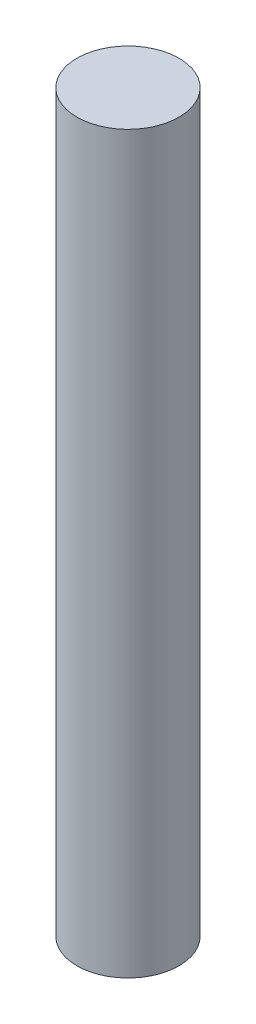
from build123d import *

# Parameters (mm, degrees)
SKETCH1_R           = 3.175
BOSS_EXTRUDE1_DEPTH = 45.72


with BuildPart() as part:
    # Sketch1 → Boss-Extrude1 (new body)
    with BuildSketch(Plane(origin=(0, 0, 0), x_dir=(1, 0, 0), z_dir=(0, 1, 0))):
        Circle(SKETCH1_R)
    extrude(amount=BOSS_EXTRUDE1_DEPTH)


solid = part.part
